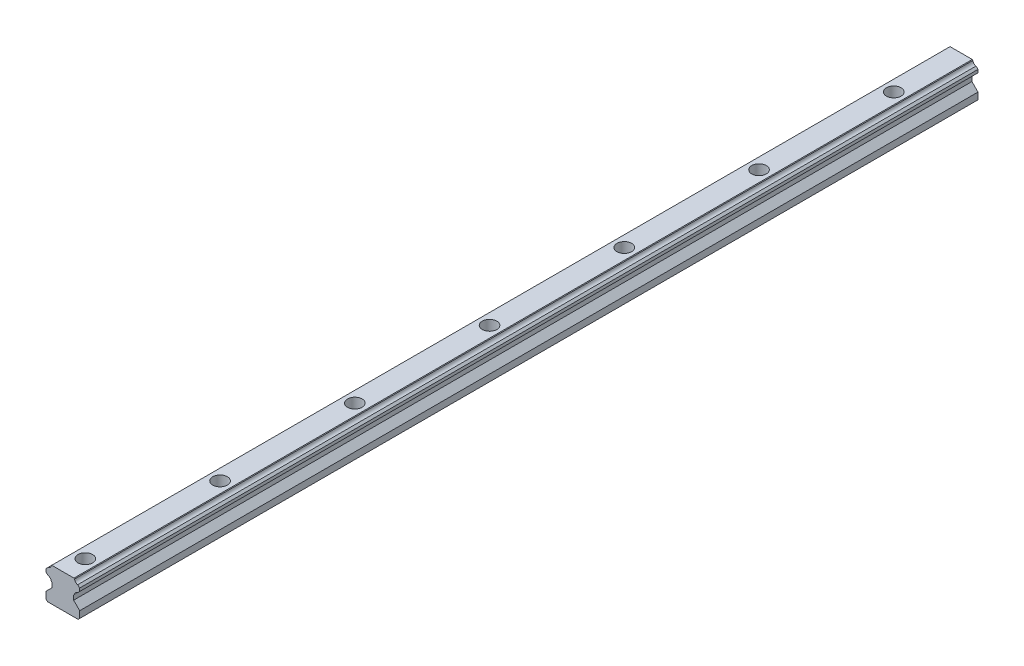
from build123d import *

# Parameters (mm, degrees)
EXTRUDE_1_DEPTH     = 400
SKETCH_2_R          = 3.25
CUT_EXTRUDE_1_DEPTH = 5.3
SKETCH_3_R          = 2.25
CUT_EXTRUDE_2_DEPTH = 10.7


with BuildPart() as part:
    # Model → Бобышка-Вытянуть1 (new body)
    with BuildSketch(Plane.XY):
        with BuildLine():
            Line((6.8, 0), (7.5, 0.7))
            Line((7.5, 0.7), (7.5, 3.6994391))
            Line((7.5, 3.6994391), (4.7998047, 6.3996344))
            Line((4.7998047, 6.3996344), (4.7998047, 8.409149262))
            Line((4.7998047, 8.409149262), (5.20075838, 8.810103152))
            ThreePointArc((5.20075838, 8.810103152), (5.668922208, 9.789261508), (6.648080611, 10.257425237))
            Line((6.648080611, 10.257425237), (7.5, 11.109345046))
            Line((7.5, 11.109345046), (7.5, 12.449454443))
            Line((7.5, 12.449454443), (6.634490912, 13.314965186))
            ThreePointArc((6.634490912, 13.314965186), (5.668922174, 13.781617126), (5.202270193, 14.747185846))
            Line((5.202270193, 14.747185846), (4.949456226, 15))
            Line((4.949456226, 15), (-4.949456226, 15))
            Line((-4.949456226, 15), (-5.202270193, 14.747185846))
            ThreePointArc((-5.202270193, 14.747185846), (-5.668922174, 13.781617126), (-6.634490912, 13.314965186))
            Line((-6.634490912, 13.314965186), (-7.5, 12.449454443))
            Line((-7.5, 12.449454443), (-7.5, 11.109345046))
            Line((-7.5, 11.109345046), (-6.648080611, 10.257425238))
            ThreePointArc((-6.648080611, 10.257425238), (-5.668922208, 9.789261508), (-5.20075838, 8.810103152))
            Line((-5.20075838, 8.810103152), (-4.7998047, 8.409149262))
            Line((-4.7998047, 8.409149262), (-4.7998047, 6.3996344))
            Line((-4.7998047, 6.3996344), (-7.5, 3.6994391))
            Line((-7.5, 3.6994391), (-7.5, 0.7))
            Line((-7.5, 0.7), (-6.8, 0))
            Line((-6.8, 0), (6.8, 0))
        make_face()
    extrude(amount=EXTRUDE_1_DEPTH)

    # Эскиз2 → Вырез-Вытянуть1 (cut)
    with BuildSketch(Plane(origin=(0, 15, 0), x_dir=(1, 0, 0), z_dir=(0, 1, 0))):
        with Locations((0, -30)):
            Circle(SKETCH_2_R)
        with Locations((0, -90)):
            Circle(SKETCH_2_R)
        with Locations((0, -150)):
            Circle(SKETCH_2_R)
        with Locations((0, -210)):
            Circle(SKETCH_2_R)
        with Locations((0, -270)):
            Circle(SKETCH_2_R)
        with Locations((0, -330)):
            Circle(SKETCH_2_R)
        with Locations((0, -390)):
            Circle(SKETCH_2_R)
        with Locations((0, -450)):
            Circle(SKETCH_2_R)
        with Locations((0, -510)):
            Circle(SKETCH_2_R)
        with Locations((0, -570)):
            Circle(SKETCH_2_R)
    extrude(amount=-CUT_EXTRUDE_1_DEPTH, mode=Mode.SUBTRACT)

    # Эскиз3 → Вырез-Вытянуть2 (cut, through all)
    with BuildSketch(Plane(origin=(0, 9.7, 0), x_dir=(1, 0, 0), z_dir=(0, 1, 0))):
        with Locations((0, -30)):
            Circle(SKETCH_3_R)
        with Locations((0, -90)):
            Circle(SKETCH_3_R)
        with Locations((0, -150)):
            Circle(SKETCH_3_R)
        with Locations((0, -210)):
            Circle(SKETCH_3_R)
        with Locations((0, -270)):
            Circle(SKETCH_3_R)
        with Locations((0, -330)):
            Circle(SKETCH_3_R)
        with Locations((0, -390)):
            Circle(SKETCH_3_R)
        with Locations((0, -450)):
            Circle(SKETCH_3_R)
        with Locations((0, -510)):
            Circle(SKETCH_3_R)
        with Locations((0, -570)):
            Circle(SKETCH_3_R)
    extrude(amount=-CUT_EXTRUDE_2_DEPTH, mode=Mode.SUBTRACT)


solid = part.part
